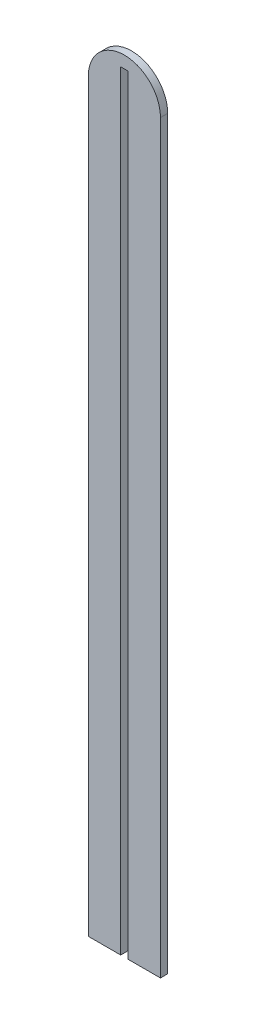
from build123d import *

# Parameters (mm, degrees)
BOSS_EXTRUDE1_DEPTH = 1.5


with BuildPart() as part:
    # Sketch2 → Boss-Extrude1 (new body, symmetric)
    with BuildSketch(Plane.XY):
        with BuildLine():
            Line((-15.000000098, -155.000001017), (-1.550000098, -155.000001017))
            Line((-1.550000098, -155.000001017), (-1.550000098, 164.999998983))
            Line((-1.550000098, 164.999998983), (1.549999902, 164.999998983))
            Line((1.549999902, 164.999998983), (1.549999902, -155.000001017))
            Line((1.549999902, -155.000001017), (14.999999902, -155.000001017))
            Line((14.999999902, -155.000001017), (14.999999902, 154.999998983))
            ThreePointArc((14.999999902, 154.999998983), (1.936e-06, 170.000001017), (-15.000000098, 155.000003052))
            Line((-15.000000098, 155.000003052), (-15.000000098, -155.000001017))
        make_face()
    extrude(amount=BOSS_EXTRUDE1_DEPTH, both=True)


solid = part.part
